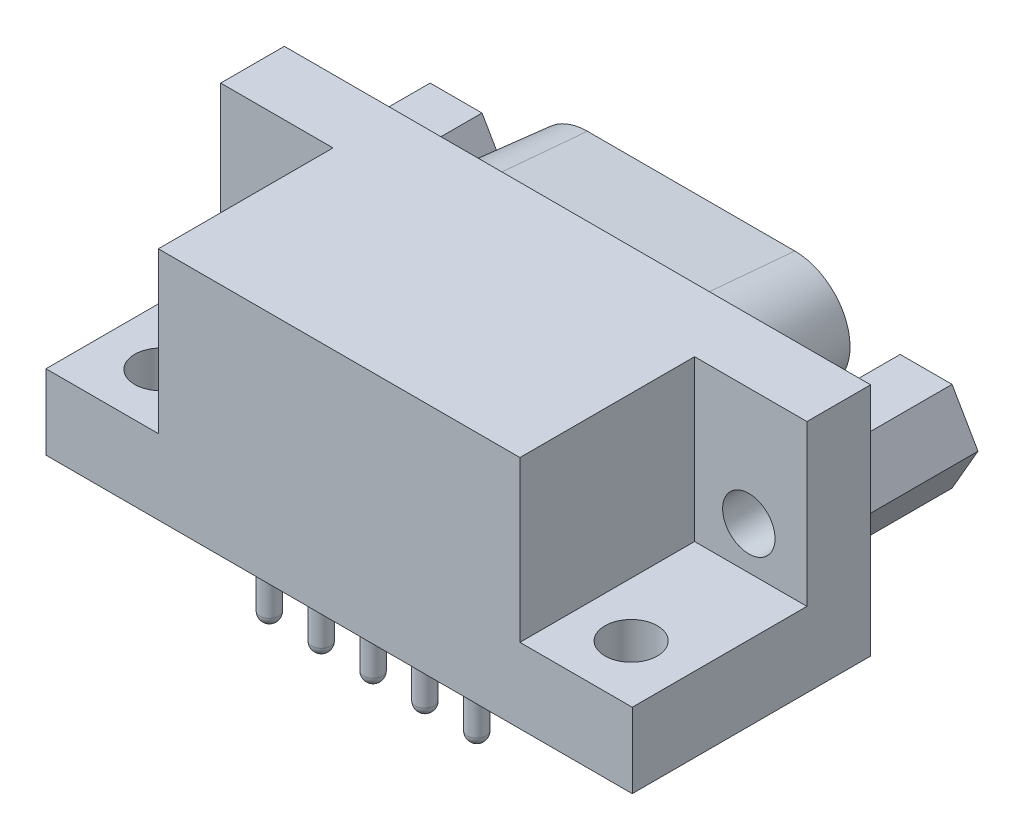
from build123d import *

# Parameters (mm, degrees)
SKETCH1_W                    = 31.314
SKETCH1_H                    = 12.55
BOARD_OUTLINE_DEPTH          = 1.77
BOARD_OUTLINE_DEPTH_BACK     = 10.96
SKETCH2_W                    = 7
SKETCH2_H                    = 10
CUT_EXTRUDE1_DEPTH           = 8.55
SKETCH4_R                    = 1.4
CUT_EXTRUDE3_DEPTH           = 26.384280569
SKETCH5_R                    = 1.4
CUT_EXTRUDE4_DEPTH           = 3
BOSS_EXTRUDE1_DEPTH          = 6.07
SKETCH7_R                    = 1.4
CUT_EXTRUDE5_DEPTH           = 6.07
BOSS_EXTRUDE3_DEPTH          = 6.07
BOSS_EXTRUDE3_TAPER          = 5
CUT_EXTRUDE7_DEPTH           = 6.07
CUT_EXTRUDE7_DRAFT           = 5
BOSS_EXTRUDE4_DEPTH          = 0.6
CUT_EXTRUDE8_START           = -0.6
SKETCH14_R                   = 0.75
CUT_EXTRUDE8_DEPTH           = 0.6
LPATTERN1_COUNT              = 4
LPATTERN1_PITCH              = 2.77
CUT_EXTRUDE9_START           = -0.6
SKETCH15_R                   = 0.75
CUT_EXTRUDE9_DEPTH           = 0.6
LPATTERN2_COUNT              = 5
LPATTERN2_PITCH              = 2.77
SKETCH16_R                   = 0.5
BOSS_EXTRUDE5_DEPTH          = 4.6
DOME1_FACE_RADIUS            = 0.5
DOME1_HEIGHT                 = 0.5
LPATTERN3_COUNT              = 4
LPATTERN3_PITCH              = 2.77
LPATTERN3_COPY_1_FACE_RADIUS = 0.5
LPATTERN3_COPY_1_HEIGHT      = 0.5
LPATTERN3_COPY_2_FACE_RADIUS = 0.5
LPATTERN3_COPY_2_HEIGHT      = 0.5
LPATTERN3_COPY_3_FACE_RADIUS = 0.5
LPATTERN3_COPY_3_HEIGHT      = 0.5
SKETCH17_R                   = 0.5
BOSS_EXTRUDE6_DEPTH          = 4.6
DOME2_FACE_RADIUS            = 0.5
DOME2_HEIGHT                 = 0.5
LPATTERN5_COUNT              = 5
LPATTERN5_PITCH              = 2.77
LPATTERN5_COPY_1_FACE_RADIUS = 0.5
LPATTERN5_COPY_1_HEIGHT      = 0.5
LPATTERN5_COPY_2_FACE_RADIUS = 0.5
LPATTERN5_COPY_2_HEIGHT      = 0.5
LPATTERN5_COPY_3_FACE_RADIUS = 0.5
LPATTERN5_COPY_3_HEIGHT      = 0.5
LPATTERN5_COPY_4_FACE_RADIUS = 0.5
LPATTERN5_COPY_4_HEIGHT      = 0.5
SKETCH18_R                   = 0.5
BOSS_EXTRUDE7_DEPTH          = 3
DOME3_FACE_RADIUS            = 0.5
DOME3_HEIGHT                 = 0.5
LPATTERN7_COUNT              = 5
LPATTERN7_PITCH              = 2.77
LPATTERN7_COPY_1_FACE_RADIUS = 0.5
LPATTERN7_COPY_1_HEIGHT      = 0.5
LPATTERN7_COPY_2_FACE_RADIUS = 0.5
LPATTERN7_COPY_2_HEIGHT      = 0.5
LPATTERN7_COPY_3_FACE_RADIUS = 0.5
LPATTERN7_COPY_3_HEIGHT      = 0.5
LPATTERN7_COPY_4_FACE_RADIUS = 0.5
LPATTERN7_COPY_4_HEIGHT      = 0.5
SKETCH19_R                   = 0.5
BOSS_EXTRUDE8_DEPTH          = 3
DOME4_FACE_RADIUS            = 0.5
DOME4_HEIGHT                 = 0.5
LPATTERN9_COUNT              = 4
LPATTERN9_PITCH              = 2.77
LPATTERN9_COPY_1_FACE_RADIUS = 0.5
LPATTERN9_COPY_1_HEIGHT      = 0.5
LPATTERN9_COPY_2_FACE_RADIUS = 0.5
LPATTERN9_COPY_2_HEIGHT      = 0.5
LPATTERN9_COPY_3_FACE_RADIUS = 0.5
LPATTERN9_COPY_3_HEIGHT      = 0.5


with BuildPart() as part:
    # Sketch1 → Board_Outline (new, two sides)
    with BuildSketch(Plane.XY) as board_outline_sk:
        with Locations((-5.583, 6.275)):
            Rectangle(SKETCH1_W, SKETCH1_H)
    extrude(amount=BOARD_OUTLINE_DEPTH)
    extrude(board_outline_sk.sketch, amount=-BOARD_OUTLINE_DEPTH_BACK)

    # Sketch2 → Cut-Extrude1 (cut)
    with BuildSketch(Plane(origin=(0, 12.55, 0), x_dir=(-1, 0, 0), z_dir=(0, 1, 0))):
        with Locations((-7.574, -2.56)):
            Rectangle(SKETCH2_W, SKETCH2_H)
    cut_extrude1 = extrude(amount=-CUT_EXTRUDE1_DEPTH, mode=Mode.SUBTRACT)

    # Sketch4 → Cut-Extrude3 (cut, through all)
    with BuildSketch(Plane(origin=(0, 4, 0), x_dir=(-1, 0, 0), z_dir=(0, 1, 0))):
        with Locations(Location((-6.975, -1.27, 0), (0, 0, 90))):
            Circle(SKETCH4_R)
    cut_extrude3 = extrude(amount=-CUT_EXTRUDE3_DEPTH, mode=Mode.SUBTRACT)

    # Sketch5 → Cut-Extrude4 (cut)
    with BuildSketch(Plane.XY.offset(-7.56)):
        with Locations((6.97, 6.275)):
            Circle(SKETCH5_R)
    cut_extrude4 = extrude(amount=-CUT_EXTRUDE4_DEPTH, mode=Mode.SUBTRACT)

    # Sketch6 → Boss-Extrude1 (add)
    with BuildSketch(Plane(origin=(0, 0, -10.96), x_dir=(-1, 0, 0), z_dir=(0, 0, -1))):
        Polygon((-5.584359354, 8.675), (-8.355640646, 8.675), (-9.741281292, 6.275), (-8.355640646, 3.875), (-5.584359354, 3.875), (-4.198718708, 6.275), align=None)
    boss_extrude1 = extrude(amount=BOSS_EXTRUDE1_DEPTH)

    # Sketch7 → Cut-Extrude5 (cut)
    with BuildSketch(Plane(origin=(0, 0, -17.03), x_dir=(-1, 0, 0), z_dir=(0, 0, -1))):
        with Locations(Location((-6.97, 6.275, 0), (0, 0, 180))):
            Circle(SKETCH7_R)
    cut_extrude5 = extrude(amount=-CUT_EXTRUDE5_DEPTH, mode=Mode.SUBTRACT)

    # Mirror1: Cut-Extrude1, Cut-Extrude3, Cut-Extrude4, Boss-Extrude1, Cut-Extrude5 across plane
    add(cut_extrude1.mirror(Plane(origin=(-5.583, 0, 0), x_dir=(0, 0, 1), z_dir=(1, 0, 0))), mode=Mode.SUBTRACT)
    add(cut_extrude3.mirror(Plane(origin=(-5.583, 0, 0), x_dir=(0, 0, 1), z_dir=(1, 0, 0))), mode=Mode.SUBTRACT)
    add(cut_extrude4.mirror(Plane(origin=(-5.583, 0, 0), x_dir=(0, 0, 1), z_dir=(1, 0, 0))), mode=Mode.SUBTRACT)
    add(boss_extrude1.mirror(Plane(origin=(-5.583, 0, 0), x_dir=(0, 0, 1), z_dir=(1, 0, 0))))
    add(cut_extrude5.mirror(Plane(origin=(-5.583, 0, 0), x_dir=(0, 0, 1), z_dir=(1, 0, 0))), mode=Mode.SUBTRACT)

    # Sketch8 → Boss-Extrude3 (add)
    with BuildSketch(Plane(origin=(0, 0, -10.96), x_dir=(-1, 0, 0), z_dir=(0, 0, -1))):
        with BuildLine():
            ThreePointArc((9.738, 1.3739), (11.582769362, 1.902901897), (12.866861644, 3.329129093))
            Line((12.866861644, 3.329129093), (14.251861644, 6.169129093))
            ThreePointArc((14.251861644, 6.169129093), (14.075098103, 9.539769362), (11.123, 11.1761))
            Line((11.123, 11.1761), (0.043, 11.1761))
            ThreePointArc((0.043, 11.1761), (-2.909098103, 9.539769362), (-3.085861644, 6.169129093))
            Line((-3.085861644, 6.169129093), (-1.700861644, 3.329129093))
            ThreePointArc((-1.700861644, 3.329129093), (-0.416769362, 1.902901897), (1.428, 1.3739))
            Line((1.428, 1.3739), (9.738, 1.3739))
        make_face()
    extrude(amount=BOSS_EXTRUDE3_DEPTH, taper=BOSS_EXTRUDE3_TAPER)


with BuildPart() as cut_extrude7_tool:
    # Sketch12 → Cut-Extrude7 (with draft: the straight prism first)
    with BuildSketch(Plane(origin=(0, 0, -17.03), x_dir=(-1, 0, 0), z_dir=(0, 0, -1))):
        with BuildLine():
            Line((-2.249015246, 6.577239044), (-0.864015246, 3.737239044))
            ThreePointArc((-0.864015246, 3.737239044), (0.076633278, 2.692471057), (1.428, 2.304956188))
            Line((1.428, 2.304956188), (9.738, 2.304956188))
            ThreePointArc((9.738, 2.304956188), (11.089366722, 2.692471057), (12.030015246, 3.737239044))
            Line((12.030015246, 3.737239044), (13.415015246, 6.577239044))
            ThreePointArc((13.415015246, 6.577239044), (13.285528943, 9.046366722), (11.123, 10.245043812))
            Line((11.123, 10.245043812), (0.043, 10.245043812))
            ThreePointArc((0.043, 10.245043812), (-2.119528943, 9.046366722), (-2.249015246, 6.577239044))
        make_face()
    extrude(amount=-CUT_EXTRUDE7_DEPTH)
    # Cut-Extrude7: the draft: its side faces are tilted about the plane it starts from
    cut_extrude7_sides = [cut_extrude7_tool.faces().sort_by_distance(p)[0] for p in [
        (1.556515246, 5.157239044, -13.995),
        (-0.076633278, 2.692471057, -13.995),
        (-5.583, 2.304956188, -13.995),
        (-11.089366722, 2.692471057, -13.995),
        (-12.722515246, 5.157239044, -13.995),
        (-13.285528943, 9.046366722, -13.995),
        (-5.583, 10.245043812, -13.995),
        (2.119528943, 9.046366722, -13.995),
    ]]
    draft(cut_extrude7_sides, Plane(origin=(0, 0, -17.03), x_dir=(-1, 0, 0), z_dir=(0, 0, -1)), CUT_EXTRUDE7_DRAFT)


with BuildPart() as part_1:
    add(part.part)

    # Cut-Extrude7: cut by cut_extrude7_tool
    add(cut_extrude7_tool.part, mode=Mode.SUBTRACT)

    # Sketch13 → Boss-Extrude4 (add)
    with BuildSketch(Plane(origin=(0, 0, -10.96), x_dir=(-1, 0, 0), z_dir=(0, 0, -1))):
        with BuildLine():
            Line((-2.239987726, 6.581641549), (-0.854987726, 3.741641549))
            ThreePointArc((-0.854987726, 3.741641549), (0.081955882, 2.700988572), (1.428, 2.315))
            Line((1.428, 2.315), (9.738, 2.315))
            ThreePointArc((9.738, 2.315), (11.084044118, 2.700988572), (12.020987726, 3.741641549))
            Line((12.020987726, 3.741641549), (13.405987726, 6.581641549))
            ThreePointArc((13.405987726, 6.581641549), (13.277011428, 9.041044118), (11.123, 10.235))
            Line((11.123, 10.235), (0.043, 10.235))
            ThreePointArc((0.043, 10.235), (-2.111011428, 9.041044118), (-2.239987726, 6.581641549))
        make_face()
    extrude(amount=BOSS_EXTRUDE4_DEPTH)

    # Sketch14 → Cut-Extrude8 (cut)
    with BuildSketch(Plane(origin=(0, 0, -11.56), x_dir=(-1, 0, 0), z_dir=(0, 0, -1)).offset(CUT_EXTRUDE8_START)):
        with Locations((1.428, 4.855)):
            Circle(SKETCH14_R)
    cut_extrude8 = extrude(amount=CUT_EXTRUDE8_DEPTH, mode=Mode.SUBTRACT)

    # LPattern1: Cut-Extrude8 ×4
    with Locations(*[(-i * LPATTERN1_PITCH, 0, 0) for i in range(1, LPATTERN1_COUNT)]):
        add(cut_extrude8, mode=Mode.SUBTRACT)

    # Sketch15 → Cut-Extrude9 (cut)
    with BuildSketch(Plane(origin=(0, 0, -11.56), x_dir=(-1, 0, 0), z_dir=(0, 0, -1)).offset(CUT_EXTRUDE9_START)):
        with Locations((0.043, 7.695)):
            Circle(SKETCH15_R)
    cut_extrude9 = extrude(amount=CUT_EXTRUDE9_DEPTH, mode=Mode.SUBTRACT)

    # LPattern2: Cut-Extrude9 ×5
    with Locations(*[(-i * LPATTERN2_PITCH, 0, 0) for i in range(1, LPATTERN2_COUNT)]):
        add(cut_extrude9, mode=Mode.SUBTRACT)

    # Sketch16 → Boss-Extrude5 (add)
    with BuildSketch(Plane(origin=(0, 0, -10.96), x_dir=(-1, 0, 0), z_dir=(0, 0, -1))):
        with Locations(Location((1.428, 4.855, 0), (0, 0, 180))):
            Circle(SKETCH16_R)
    boss_extrude5 = extrude(amount=BOSS_EXTRUDE5_DEPTH)

    # Dome1: a dome of height H over a round flat face of radius A is a cap of a sphere of radius (A * A + H * H) / (2 * H)
    dome1_r = (DOME1_FACE_RADIUS * DOME1_FACE_RADIUS + DOME1_HEIGHT * DOME1_HEIGHT) / (2 * DOME1_HEIGHT)
    dome1_base = Plane((-1.428, 4.855, -15.56), z_dir=(0, 0, -1))
    with Locations(dome1_base.offset(DOME1_HEIGHT - dome1_r)):
        dome1_ball = Sphere(dome1_r, mode=Mode.PRIVATE)
    add(split(dome1_ball, bisect_by=dome1_base, keep=Keep.TOP, mode=Mode.PRIVATE))

    # LPattern3: Boss-Extrude5 ×4
    with Locations(*[(-i * LPATTERN3_PITCH, 0, 0) for i in range(1, LPATTERN3_COUNT)]):
        add(boss_extrude5)

    # LPattern3 copy 1: a dome of height H over a round flat face of radius A is a cap of a sphere of radius (A * A + H * H) / (2 * H)
    lpattern3_copy_1_r = (LPATTERN3_COPY_1_FACE_RADIUS * LPATTERN3_COPY_1_FACE_RADIUS + LPATTERN3_COPY_1_HEIGHT * LPATTERN3_COPY_1_HEIGHT) / (2 * LPATTERN3_COPY_1_HEIGHT)
    lpattern3_copy_1_base = Plane((-4.198, 4.855, -15.56), z_dir=(0, 0, -1))
    with Locations(lpattern3_copy_1_base.offset(LPATTERN3_COPY_1_HEIGHT - lpattern3_copy_1_r)):
        lpattern3_copy_1_ball = Sphere(lpattern3_copy_1_r, mode=Mode.PRIVATE)
    add(split(lpattern3_copy_1_ball, bisect_by=lpattern3_copy_1_base, keep=Keep.TOP, mode=Mode.PRIVATE))

    # LPattern3 copy 2: a dome of height H over a round flat face of radius A is a cap of a sphere of radius (A * A + H * H) / (2 * H)
    lpattern3_copy_2_r = (LPATTERN3_COPY_2_FACE_RADIUS * LPATTERN3_COPY_2_FACE_RADIUS + LPATTERN3_COPY_2_HEIGHT * LPATTERN3_COPY_2_HEIGHT) / (2 * LPATTERN3_COPY_2_HEIGHT)
    lpattern3_copy_2_base = Plane((-6.968, 4.855, -15.56), z_dir=(0, 0, -1))
    with Locations(lpattern3_copy_2_base.offset(LPATTERN3_COPY_2_HEIGHT - lpattern3_copy_2_r)):
        lpattern3_copy_2_ball = Sphere(lpattern3_copy_2_r, mode=Mode.PRIVATE)
    add(split(lpattern3_copy_2_ball, bisect_by=lpattern3_copy_2_base, keep=Keep.TOP, mode=Mode.PRIVATE))

    # LPattern3 copy 3: a dome of height H over a round flat face of radius A is a cap of a sphere of radius (A * A + H * H) / (2 * H)
    lpattern3_copy_3_r = (LPATTERN3_COPY_3_FACE_RADIUS * LPATTERN3_COPY_3_FACE_RADIUS + LPATTERN3_COPY_3_HEIGHT * LPATTERN3_COPY_3_HEIGHT) / (2 * LPATTERN3_COPY_3_HEIGHT)
    lpattern3_copy_3_base = Plane((-9.738, 4.855, -15.56), z_dir=(0, 0, -1))
    with Locations(lpattern3_copy_3_base.offset(LPATTERN3_COPY_3_HEIGHT - lpattern3_copy_3_r)):
        lpattern3_copy_3_ball = Sphere(lpattern3_copy_3_r, mode=Mode.PRIVATE)
    add(split(lpattern3_copy_3_ball, bisect_by=lpattern3_copy_3_base, keep=Keep.TOP, mode=Mode.PRIVATE))

    # Sketch17 → Boss-Extrude6 (add)
    with BuildSketch(Plane(origin=(0, 0, -10.96), x_dir=(-1, 0, 0), z_dir=(0, 0, -1))):
        with Locations(Location((0.043, 7.695, 0), (0, 0, 180))):
            Circle(SKETCH17_R)
    boss_extrude6 = extrude(amount=BOSS_EXTRUDE6_DEPTH)

    # Dome2: a dome of height H over a round flat face of radius A is a cap of a sphere of radius (A * A + H * H) / (2 * H)
    dome2_r = (DOME2_FACE_RADIUS * DOME2_FACE_RADIUS + DOME2_HEIGHT * DOME2_HEIGHT) / (2 * DOME2_HEIGHT)
    dome2_base = Plane((-0.043, 7.695, -15.56), z_dir=(0, 0, -1))
    with Locations(dome2_base.offset(DOME2_HEIGHT - dome2_r)):
        dome2_ball = Sphere(dome2_r, mode=Mode.PRIVATE)
    add(split(dome2_ball, bisect_by=dome2_base, keep=Keep.TOP, mode=Mode.PRIVATE))

    # LPattern5: Boss-Extrude6 ×5
    with Locations(*[(-i * LPATTERN5_PITCH, 0, 0) for i in range(1, LPATTERN5_COUNT)]):
        add(boss_extrude6)

    # LPattern5 copy 1: a dome of height H over a round flat face of radius A is a cap of a sphere of radius (A * A + H * H) / (2 * H)
    lpattern5_copy_1_r = (LPATTERN5_COPY_1_FACE_RADIUS * LPATTERN5_COPY_1_FACE_RADIUS + LPATTERN5_COPY_1_HEIGHT * LPATTERN5_COPY_1_HEIGHT) / (2 * LPATTERN5_COPY_1_HEIGHT)
    lpattern5_copy_1_base = Plane((-2.813, 7.695, -15.56), z_dir=(0, 0, -1))
    with Locations(lpattern5_copy_1_base.offset(LPATTERN5_COPY_1_HEIGHT - lpattern5_copy_1_r)):
        lpattern5_copy_1_ball = Sphere(lpattern5_copy_1_r, mode=Mode.PRIVATE)
    add(split(lpattern5_copy_1_ball, bisect_by=lpattern5_copy_1_base, keep=Keep.TOP, mode=Mode.PRIVATE))

    # LPattern5 copy 2: a dome of height H over a round flat face of radius A is a cap of a sphere of radius (A * A + H * H) / (2 * H)
    lpattern5_copy_2_r = (LPATTERN5_COPY_2_FACE_RADIUS * LPATTERN5_COPY_2_FACE_RADIUS + LPATTERN5_COPY_2_HEIGHT * LPATTERN5_COPY_2_HEIGHT) / (2 * LPATTERN5_COPY_2_HEIGHT)
    lpattern5_copy_2_base = Plane((-5.583, 7.695, -15.56), z_dir=(0, 0, -1))
    with Locations(lpattern5_copy_2_base.offset(LPATTERN5_COPY_2_HEIGHT - lpattern5_copy_2_r)):
        lpattern5_copy_2_ball = Sphere(lpattern5_copy_2_r, mode=Mode.PRIVATE)
    add(split(lpattern5_copy_2_ball, bisect_by=lpattern5_copy_2_base, keep=Keep.TOP, mode=Mode.PRIVATE))

    # LPattern5 copy 3: a dome of height H over a round flat face of radius A is a cap of a sphere of radius (A * A + H * H) / (2 * H)
    lpattern5_copy_3_r = (LPATTERN5_COPY_3_FACE_RADIUS * LPATTERN5_COPY_3_FACE_RADIUS + LPATTERN5_COPY_3_HEIGHT * LPATTERN5_COPY_3_HEIGHT) / (2 * LPATTERN5_COPY_3_HEIGHT)
    lpattern5_copy_3_base = Plane((-8.353, 7.695, -15.56), z_dir=(0, 0, -1))
    with Locations(lpattern5_copy_3_base.offset(LPATTERN5_COPY_3_HEIGHT - lpattern5_copy_3_r)):
        lpattern5_copy_3_ball = Sphere(lpattern5_copy_3_r, mode=Mode.PRIVATE)
    add(split(lpattern5_copy_3_ball, bisect_by=lpattern5_copy_3_base, keep=Keep.TOP, mode=Mode.PRIVATE))

    # LPattern5 copy 4: a dome of height H over a round flat face of radius A is a cap of a sphere of radius (A * A + H * H) / (2 * H)
    lpattern5_copy_4_r = (LPATTERN5_COPY_4_FACE_RADIUS * LPATTERN5_COPY_4_FACE_RADIUS + LPATTERN5_COPY_4_HEIGHT * LPATTERN5_COPY_4_HEIGHT) / (2 * LPATTERN5_COPY_4_HEIGHT)
    lpattern5_copy_4_base = Plane((-11.123, 7.695, -15.56), z_dir=(0, 0, -1))
    with Locations(lpattern5_copy_4_base.offset(LPATTERN5_COPY_4_HEIGHT - lpattern5_copy_4_r)):
        lpattern5_copy_4_ball = Sphere(lpattern5_copy_4_r, mode=Mode.PRIVATE)
    add(split(lpattern5_copy_4_ball, bisect_by=lpattern5_copy_4_base, keep=Keep.TOP, mode=Mode.PRIVATE))

    # Sketch18 → Boss-Extrude7 (add)
    with BuildSketch(Plane.XZ):
        with Locations(Location((0, 0, 0), (0, 0, 90))):
            Circle(SKETCH18_R)
    boss_extrude7 = extrude(amount=BOSS_EXTRUDE7_DEPTH)

    # Dome3: a dome of height H over a round flat face of radius A is a cap of a sphere of radius (A * A + H * H) / (2 * H)
    dome3_r = (DOME3_FACE_RADIUS * DOME3_FACE_RADIUS + DOME3_HEIGHT * DOME3_HEIGHT) / (2 * DOME3_HEIGHT)
    dome3_base = Plane((0, -3, 0), z_dir=(0, -1, 0))
    with Locations(dome3_base.offset(DOME3_HEIGHT - dome3_r)):
        dome3_ball = Sphere(dome3_r, mode=Mode.PRIVATE)
    add(split(dome3_ball, bisect_by=dome3_base, keep=Keep.TOP, mode=Mode.PRIVATE))

    # LPattern7: Boss-Extrude7 ×5
    with Locations(*[(-i * LPATTERN7_PITCH, 0, 0) for i in range(1, LPATTERN7_COUNT)]):
        add(boss_extrude7)

    # LPattern7 copy 1: a dome of height H over a round flat face of radius A is a cap of a sphere of radius (A * A + H * H) / (2 * H)
    lpattern7_copy_1_r = (LPATTERN7_COPY_1_FACE_RADIUS * LPATTERN7_COPY_1_FACE_RADIUS + LPATTERN7_COPY_1_HEIGHT * LPATTERN7_COPY_1_HEIGHT) / (2 * LPATTERN7_COPY_1_HEIGHT)
    lpattern7_copy_1_base = Plane((-2.77, -3, 0), z_dir=(0, -1, 0))
    with Locations(lpattern7_copy_1_base.offset(LPATTERN7_COPY_1_HEIGHT - lpattern7_copy_1_r)):
        lpattern7_copy_1_ball = Sphere(lpattern7_copy_1_r, mode=Mode.PRIVATE)
    add(split(lpattern7_copy_1_ball, bisect_by=lpattern7_copy_1_base, keep=Keep.TOP, mode=Mode.PRIVATE))

    # LPattern7 copy 2: a dome of height H over a round flat face of radius A is a cap of a sphere of radius (A * A + H * H) / (2 * H)
    lpattern7_copy_2_r = (LPATTERN7_COPY_2_FACE_RADIUS * LPATTERN7_COPY_2_FACE_RADIUS + LPATTERN7_COPY_2_HEIGHT * LPATTERN7_COPY_2_HEIGHT) / (2 * LPATTERN7_COPY_2_HEIGHT)
    lpattern7_copy_2_base = Plane((-5.54, -3, 0), z_dir=(0, -1, 0))
    with Locations(lpattern7_copy_2_base.offset(LPATTERN7_COPY_2_HEIGHT - lpattern7_copy_2_r)):
        lpattern7_copy_2_ball = Sphere(lpattern7_copy_2_r, mode=Mode.PRIVATE)
    add(split(lpattern7_copy_2_ball, bisect_by=lpattern7_copy_2_base, keep=Keep.TOP, mode=Mode.PRIVATE))

    # LPattern7 copy 3: a dome of height H over a round flat face of radius A is a cap of a sphere of radius (A * A + H * H) / (2 * H)
    lpattern7_copy_3_r = (LPATTERN7_COPY_3_FACE_RADIUS * LPATTERN7_COPY_3_FACE_RADIUS + LPATTERN7_COPY_3_HEIGHT * LPATTERN7_COPY_3_HEIGHT) / (2 * LPATTERN7_COPY_3_HEIGHT)
    lpattern7_copy_3_base = Plane((-8.31, -3, 0), z_dir=(0, -1, 0))
    with Locations(lpattern7_copy_3_base.offset(LPATTERN7_COPY_3_HEIGHT - lpattern7_copy_3_r)):
        lpattern7_copy_3_ball = Sphere(lpattern7_copy_3_r, mode=Mode.PRIVATE)
    add(split(lpattern7_copy_3_ball, bisect_by=lpattern7_copy_3_base, keep=Keep.TOP, mode=Mode.PRIVATE))

    # LPattern7 copy 4: a dome of height H over a round flat face of radius A is a cap of a sphere of radius (A * A + H * H) / (2 * H)
    lpattern7_copy_4_r = (LPATTERN7_COPY_4_FACE_RADIUS * LPATTERN7_COPY_4_FACE_RADIUS + LPATTERN7_COPY_4_HEIGHT * LPATTERN7_COPY_4_HEIGHT) / (2 * LPATTERN7_COPY_4_HEIGHT)
    lpattern7_copy_4_base = Plane((-11.08, -3, 0), z_dir=(0, -1, 0))
    with Locations(lpattern7_copy_4_base.offset(LPATTERN7_COPY_4_HEIGHT - lpattern7_copy_4_r)):
        lpattern7_copy_4_ball = Sphere(lpattern7_copy_4_r, mode=Mode.PRIVATE)
    add(split(lpattern7_copy_4_ball, bisect_by=lpattern7_copy_4_base, keep=Keep.TOP, mode=Mode.PRIVATE))

    # Sketch19 → Boss-Extrude8 (add)
    with BuildSketch(Plane.XZ):
        with Locations(Location((-1.38, -2.84, 0), (0, 0, 90))):
            Circle(SKETCH19_R)
    boss_extrude8 = extrude(amount=BOSS_EXTRUDE8_DEPTH)

    # Dome4: a dome of height H over a round flat face of radius A is a cap of a sphere of radius (A * A + H * H) / (2 * H)
    dome4_r = (DOME4_FACE_RADIUS * DOME4_FACE_RADIUS + DOME4_HEIGHT * DOME4_HEIGHT) / (2 * DOME4_HEIGHT)
    dome4_base = Plane((-1.38, -3, -2.84), z_dir=(0, -1, 0))
    with Locations(dome4_base.offset(DOME4_HEIGHT - dome4_r)):
        dome4_ball = Sphere(dome4_r, mode=Mode.PRIVATE)
    add(split(dome4_ball, bisect_by=dome4_base, keep=Keep.TOP, mode=Mode.PRIVATE))

    # LPattern9: Boss-Extrude8 ×4
    with Locations(*[(-i * LPATTERN9_PITCH, 0, 0) for i in range(1, LPATTERN9_COUNT)]):
        add(boss_extrude8)

    # LPattern9 copy 1: a dome of height H over a round flat face of radius A is a cap of a sphere of radius (A * A + H * H) / (2 * H)
    lpattern9_copy_1_r = (LPATTERN9_COPY_1_FACE_RADIUS * LPATTERN9_COPY_1_FACE_RADIUS + LPATTERN9_COPY_1_HEIGHT * LPATTERN9_COPY_1_HEIGHT) / (2 * LPATTERN9_COPY_1_HEIGHT)
    lpattern9_copy_1_base = Plane((-4.15, -3, -2.84), z_dir=(0, -1, 0))
    with Locations(lpattern9_copy_1_base.offset(LPATTERN9_COPY_1_HEIGHT - lpattern9_copy_1_r)):
        lpattern9_copy_1_ball = Sphere(lpattern9_copy_1_r, mode=Mode.PRIVATE)
    add(split(lpattern9_copy_1_ball, bisect_by=lpattern9_copy_1_base, keep=Keep.TOP, mode=Mode.PRIVATE))

    # LPattern9 copy 2: a dome of height H over a round flat face of radius A is a cap of a sphere of radius (A * A + H * H) / (2 * H)
    lpattern9_copy_2_r = (LPATTERN9_COPY_2_FACE_RADIUS * LPATTERN9_COPY_2_FACE_RADIUS + LPATTERN9_COPY_2_HEIGHT * LPATTERN9_COPY_2_HEIGHT) / (2 * LPATTERN9_COPY_2_HEIGHT)
    lpattern9_copy_2_base = Plane((-6.92, -3, -2.84), z_dir=(0, -1, 0))
    with Locations(lpattern9_copy_2_base.offset(LPATTERN9_COPY_2_HEIGHT - lpattern9_copy_2_r)):
        lpattern9_copy_2_ball = Sphere(lpattern9_copy_2_r, mode=Mode.PRIVATE)
    add(split(lpattern9_copy_2_ball, bisect_by=lpattern9_copy_2_base, keep=Keep.TOP, mode=Mode.PRIVATE))

    # LPattern9 copy 3: a dome of height H over a round flat face of radius A is a cap of a sphere of radius (A * A + H * H) / (2 * H)
    lpattern9_copy_3_r = (LPATTERN9_COPY_3_FACE_RADIUS * LPATTERN9_COPY_3_FACE_RADIUS + LPATTERN9_COPY_3_HEIGHT * LPATTERN9_COPY_3_HEIGHT) / (2 * LPATTERN9_COPY_3_HEIGHT)
    lpattern9_copy_3_base = Plane((-9.69, -3, -2.84), z_dir=(0, -1, 0))
    with Locations(lpattern9_copy_3_base.offset(LPATTERN9_COPY_3_HEIGHT - lpattern9_copy_3_r)):
        lpattern9_copy_3_ball = Sphere(lpattern9_copy_3_r, mode=Mode.PRIVATE)
    add(split(lpattern9_copy_3_ball, bisect_by=lpattern9_copy_3_base, keep=Keep.TOP, mode=Mode.PRIVATE))


solid = part_1.part
